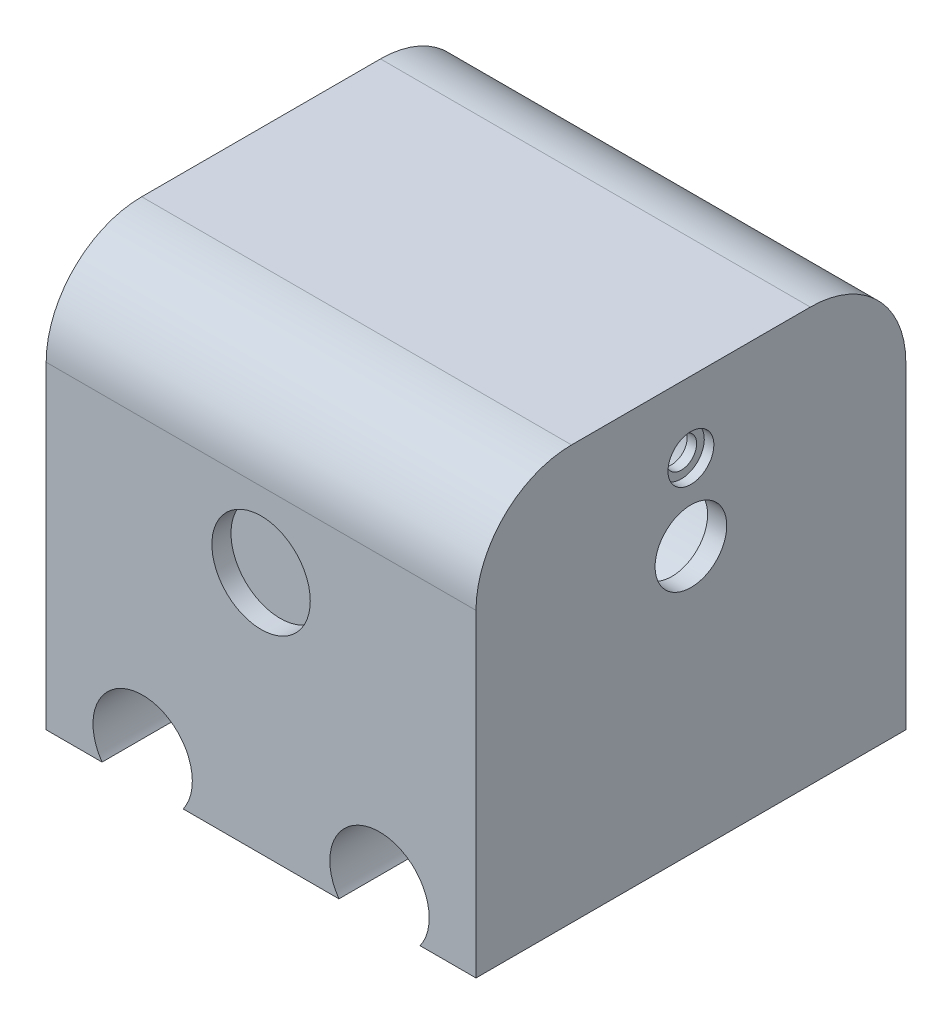
from build123d import *

# Parameters (mm, degrees)
SKETCH1_W           = 45
SKETCH1_H           = 50
BOSS_EXTRUDE1_DEPTH = 45
SKETCH2_R           = 5.2
CUT_EXTRUDE1_DEPTH  = 45
SKETCH9_R           = 5.15
CUT_EXTRUDE6_DEPTH  = 2
SKETCH10_R          = 5.15
CUT_EXTRUDE7_DEPTH  = 2
SKETCH12_R          = 12.7
CUT_EXTRUDE8_DEPTH  = 46
SKETCH13_W          = 45
SKETCH13_H          = 6.66747138
CUT_EXTRUDE9_DEPTH  = 46
SKETCH16_R          = 13.25
SKETCH16_R_2        = 3.75
BOSS_EXTRUDE3_DEPTH = 2
FILLET1_R           = 10
SKETCH17_R          = 1.6
CUT_EXTRUDE10_DEPTH = 10
SKETCH18_R          = 2.4
CUT_EXTRUDE11_DEPTH = 1


with BuildPart() as part:
    # Sketch1 → Boss-Extrude1 (new body)
    with BuildSketch(Plane.XY):
        with Locations((8.236607143, -2.901785714)):
            Rectangle(SKETCH1_W, SKETCH1_H)
    extrude(amount=BOSS_EXTRUDE1_DEPTH)

    # Sketch2 → Cut-Extrude1 (cut)
    with BuildSketch(Plane.XY.offset(45)):
        with Locations((-4.163392857, -24.901785714)):
            Circle(SKETCH2_R)
        with Locations((20.636607143, -24.901785714)):
            Circle(SKETCH2_R)
    extrude(amount=-CUT_EXTRUDE1_DEPTH, mode=Mode.SUBTRACT)

    # Sketch9 → Cut-Extrude6 (cut)
    with BuildSketch(Plane.XY.offset(45)):
        with Locations((8.236607143, -2.401785714)):
            Circle(SKETCH9_R)
    extrude(amount=-CUT_EXTRUDE6_DEPTH, mode=Mode.SUBTRACT)

    # Sketch10 → Cut-Extrude7 (cut)
    with BuildSketch(Plane(origin=(0, 0, 0), x_dir=(-1, 0, 0), z_dir=(0, 0, -1))):
        with Locations((-8.236607143, -2.401785714)):
            Circle(SKETCH10_R)
    extrude(amount=-CUT_EXTRUDE7_DEPTH, mode=Mode.SUBTRACT)

    # Sketch12 → Cut-Extrude8 (cut)
    with BuildSketch(Plane.ZY.offset(14.263392857)):
        with Locations((22.5, 0)):
            Circle(SKETCH12_R)
    extrude(amount=-CUT_EXTRUDE8_DEPTH, mode=Mode.SUBTRACT)

    # Sketch13 → Cut-Extrude9 (cut)
    with BuildSketch(Plane.ZY.offset(14.263392857)):
        with Locations((22.5, 18.764478596)):
            Rectangle(SKETCH13_W, SKETCH13_H)
    extrude(amount=-CUT_EXTRUDE9_DEPTH, mode=Mode.SUBTRACT)

    # Sketch16 → Boss-Extrude3 (add)
    with BuildSketch(Plane(origin=(30.736607143, 0, 0), x_dir=(0, 0, -1), z_dir=(1, 0, 0))):
        with Locations((-22.5, 0)):
            Circle(SKETCH16_R)
        with Locations((-22.5, 0)):
            Circle(SKETCH16_R_2, mode=Mode.SUBTRACT)
    extrude(amount=-BOSS_EXTRUDE3_DEPTH)

    # Fillet1
    fillet1_edges = [part.edges().sort_by_distance(p)[0] for p in [
        (8.236607143, 15.430742906, 0),
        (8.236607143, 15.430742906, 45),
    ]]
    fillet(fillet1_edges, radius=FILLET1_R)

    # Sketch17 → Cut-Extrude10 (cut)
    with BuildSketch(Plane(origin=(30.736607143, 0, 0), x_dir=(0, 0, -1), z_dir=(1, 0, 0))):
        with Locations((-22.5, 8)):
            Circle(SKETCH17_R)
    extrude(amount=-CUT_EXTRUDE10_DEPTH, mode=Mode.SUBTRACT)

    # Sketch18 → Cut-Extrude11 (cut)
    with BuildSketch(Plane(origin=(30.736607143, 0, 0), x_dir=(0, 0, -1), z_dir=(1, 0, 0))):
        with Locations((-22.5, 8)):
            Circle(SKETCH18_R)
    extrude(amount=-CUT_EXTRUDE11_DEPTH, mode=Mode.SUBTRACT)


solid = part.part
